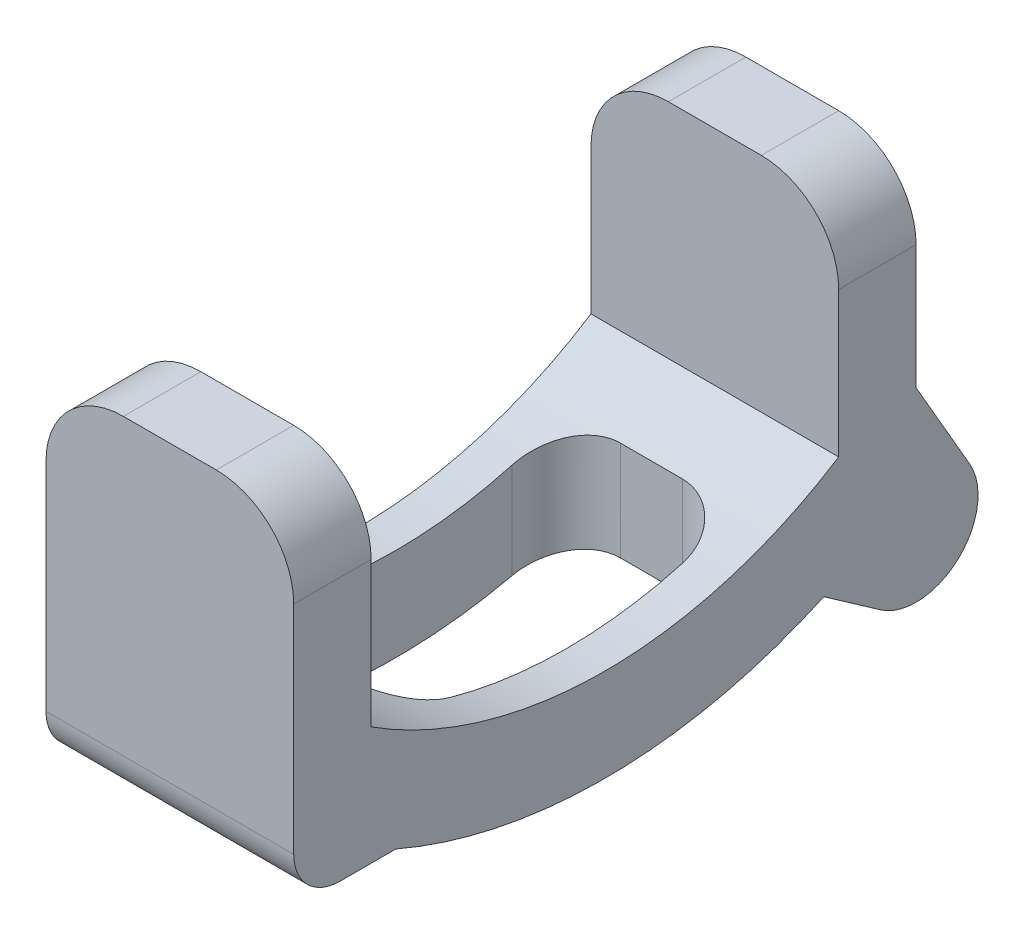
from build123d import *

# Parameters (mm, degrees)
VYSUNOUT1_DEPTH          = 8
ZAOBLIT1_R               = 5
ZAOBLIT2_R               = 3
SKICA2_W                 = 11
SKICA2_H                 = 22
ODEBRAT_VYSUNUT_M1_DEPTH = 12
ZAOBLIT3_R               = 3.5


with BuildPart() as part:
    # Skica1 → Vysunout1 (new body, symmetric)
    with BuildSketch(Plane(origin=(0, 0, 0), x_dir=(0, 0, -1), z_dir=(1, 0, 0))):
        with BuildLine():
            Line((-20.1, 0), (-20.1, 22))
            Line((-20.1, 22), (-15.1, 22))
            Line((-15.1, 22), (-15.1, 7.630965))
            ThreePointArc((-15.1, 7.630965), (-7.868346, 4.330613), (0, 3.2))
            ThreePointArc((0, 3.2), (7.868346, 4.330613), (15.1, 7.630965))
            Line((15.1, 7.630965), (15.1, 22))
            Line((15.1, 22), (20.1, 22))
            Line((20.1, 22), (20.1, 9))
            Line((20.1, 9), (23.564102, 3))
            ThreePointArc((23.564102, 3), (22.802361, -1.949109), (17.805694, -2.276608))
            Line((17.805694, -2.276608), (14.144179, 0.287213))
            ThreePointArc((14.144179, 0.287213), (7.238589, -2.019217), (0, -2.8))
            ThreePointArc((0, -2.8), (-6.893657, -2.09263), (-13.5, 0))
            Line((-13.5, 0), (-20.1, 0))
        make_face()
    extrude(amount=VYSUNOUT1_DEPTH, both=True)

    # Zaoblit1
    zaoblit1_edges = [part.edges().sort_by_distance(p)[0] for p in [
        (-8, 22, 17.6),
        (-8, 22, -17.6),
        (8, 22, -17.6),
        (8, 22, 17.6),
    ]]
    fillet(zaoblit1_edges, radius=ZAOBLIT1_R)

    # Zaoblit2
    zaoblit2_edges = [part.edges().sort_by_distance(p)[0] for p in [
        (-4, 0, 20.1),
    ]]
    fillet(zaoblit2_edges, radius=ZAOBLIT2_R)

    # Skica2 → Odebrat vysunutím1 (cut, through all)
    with BuildSketch(Plane(origin=(0, 8, 0), x_dir=(-1, 0, 0), z_dir=(0, 1, 0))):
        Rectangle(SKICA2_W, SKICA2_H)
    extrude(amount=-ODEBRAT_VYSUNUT_M1_DEPTH, mode=Mode.SUBTRACT)

    # Zaoblit3
    zaoblit3_edges = [part.edges().sort_by_distance(p)[0] for p in [
        (-5.5, 2.2439, -11),
        (5.5, 2.2439, -11),
        (5.5, 2.2439, 11),
        (-5.5, 2.2439, 11),
    ]]
    fillet(zaoblit3_edges, radius=ZAOBLIT3_R)


solid = part.part
